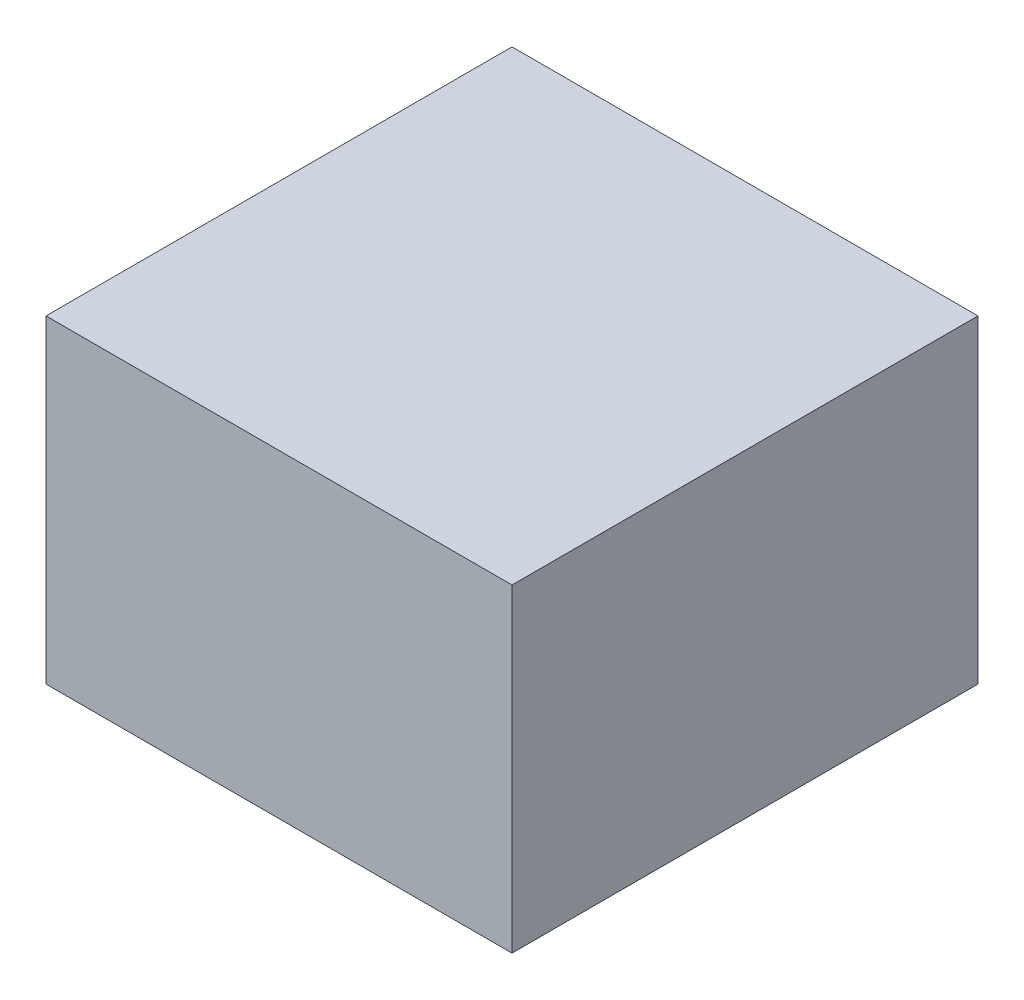
from build123d import *

# Parameters (mm, degrees)
SKETCH2_W           = 190
SKETCH2_H           = 190
BOSS_EXTRUDE1_DEPTH = 130
SKETCH3_W           = 170
SKETCH3_H           = 110
BOSS_EXTRUDE2_DEPTH = 2
SKETCH4_R           = 4
BOSS_EXTRUDE3_DEPTH = 8


with BuildPart() as part:
    # Sketch2 → Boss-Extrude1 (new body)
    with BuildSketch(Plane(origin=(0, 0, 0), x_dir=(1, 0, 0), z_dir=(0, 1, 0))):
        with Locations((37.344584985, 55)):
            Rectangle(SKETCH2_W, SKETCH2_H)
    extrude(amount=BOSS_EXTRUDE1_DEPTH)

    # Sketch3 → Boss-Extrude2 (add)
    with BuildSketch(Plane.ZY.offset(57.655415015)):
        with Locations((-55, 65)):
            Rectangle(SKETCH3_W, SKETCH3_H)
    extrude(amount=BOSS_EXTRUDE2_DEPTH)

    # Sketch4 → Boss-Extrude3 (add)
    with BuildSketch(Plane.ZY.offset(59.655415015)):
        with Locations((-25, 25)):
            Circle(SKETCH4_R)
        with Locations((-45, 25)):
            Circle(SKETCH4_R)
        with Locations((-25, 105)):
            Circle(SKETCH4_R)
        with Locations((-65, 25)):
            Circle(SKETCH4_R)
        with Locations((-85, 25)):
            Circle(SKETCH4_R)
        with Locations((-45, 105)):
            Circle(SKETCH4_R)
        with Locations((-65, 105)):
            Circle(SKETCH4_R)
        with Locations((-85, 105)):
            Circle(SKETCH4_R)
    extrude(amount=BOSS_EXTRUDE3_DEPTH)


solid = part.part
